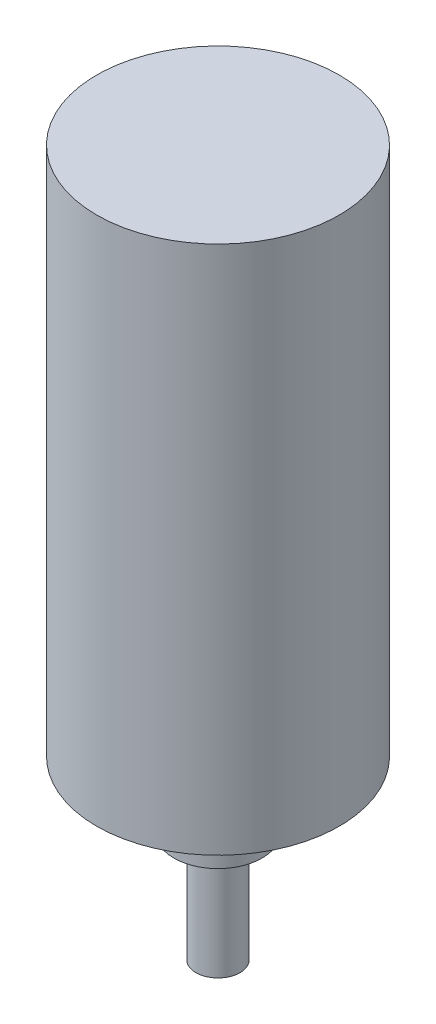
from build123d import *

# Parameters (mm, degrees)
BOSS_EXTRUDE1_DEPTH = 8
SKETCH2_R           = 2
BOSS_EXTRUDE2_DEPTH = 2
SKETCH3_R           = 4
BOSS_EXTRUDE3_DEPTH = 6
SKETCH4_R           = 11
BOSS_EXTRUDE4_DEPTH = 48


with BuildPart() as part:
    # Sketch1 → Boss-Extrude1 (new body)
    with BuildSketch(Plane(origin=(0, 0, 0), x_dir=(1, 0, 0), z_dir=(0, 1, 0))):
        with BuildLine():
            Line((-1.5, 1.322875656), (1.5, 1.322875656))
            ThreePointArc((1.5, 1.322875656), (0, -2), (-1.5, 1.322875656))
        make_face()
    extrude(amount=BOSS_EXTRUDE1_DEPTH)

    # Sketch2 → Boss-Extrude2 (add)
    with BuildSketch(Plane(origin=(0, 8, 0), x_dir=(1, 0, 0), z_dir=(0, 1, 0))):
        Circle(SKETCH2_R)
    extrude(amount=BOSS_EXTRUDE2_DEPTH)

    # Sketch3 → Boss-Extrude3 (add)
    with BuildSketch(Plane(origin=(0, 10, 0), x_dir=(1, 0, 0), z_dir=(0, 1, 0))):
        Circle(SKETCH3_R)
    extrude(amount=BOSS_EXTRUDE3_DEPTH)

    # Sketch4 → Boss-Extrude4 (add)
    with BuildSketch(Plane(origin=(0, 16, 0), x_dir=(1, 0, 0), z_dir=(0, 1, 0))):
        Circle(SKETCH4_R)
    extrude(amount=BOSS_EXTRUDE4_DEPTH)


solid = part.part
